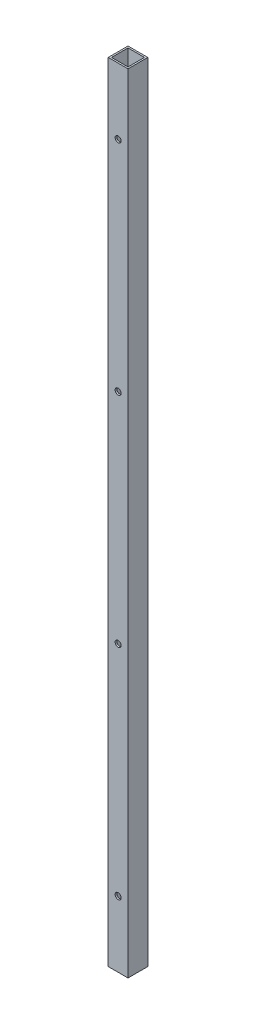
from build123d import *

# Parameters (mm, degrees)
SKETCH1_W                      = 19.05
SKETCH1_H                      = 19.05
SKETCH1_W_2                    = 15.875
SKETCH1_H_2                    = 15.875
TUBE_DEPTH                     = 758.9266
SKETCH2_R                      = 2.8956
SIDE_WALL_HOLES_DEPTH          = 20.05
LPATTERN1_COUNT                = 4
LPATTERN1_PITCH                = 210.574466667
CUT_EXTRUDE1_REACH             = 21.05
SKETCH3_R                      = 4.7625
CUT_EXTRUDE1_DIRECTION_2_DEPTH = 1


with BuildPart() as part:
    # Sketch1 → Tube (new body)
    with BuildSketch(Plane(origin=(0, 0, 0), x_dir=(1, 0, 0), z_dir=(0, 1, 0))):
        Rectangle(SKETCH1_W, SKETCH1_H)
        Rectangle(SKETCH1_W_2, SKETCH1_H_2, mode=Mode.SUBTRACT)
    extrude(amount=TUBE_DEPTH)

    # Sketch2 → Side Wall Holes (cut, through all)
    with BuildSketch(Plane.XY.offset(9.525)):
        with Locations((0, 695.325)):
            Circle(SKETCH2_R)
    side_wall_holes = extrude(amount=-SIDE_WALL_HOLES_DEPTH, mode=Mode.SUBTRACT)

    # LPattern1: Side Wall Holes ×4
    with Locations(*[(0, -i * LPATTERN1_PITCH, 0) for i in range(1, LPATTERN1_COUNT)]):
        add(side_wall_holes, mode=Mode.SUBTRACT)

    # Sketch3 → Cut-Extrude1 (cut, up to next)
    with BuildSketch(Plane.ZY.offset(9.525), mode=Mode.PRIVATE) as cut_extrude1_sk1:
        with Locations((0, 674.37)):
            Circle(SKETCH3_R)
    cut_extrude1_tool1 = extrude(cut_extrude1_sk1.sketch, amount=-CUT_EXTRUDE1_REACH, mode=Mode.PRIVATE) & part.part
    add(cut_extrude1_tool1.solids().sort_by_distance((-9.525, 674.37, 0))[0], mode=Mode.SUBTRACT)
    # Sketch3 → Cut-Extrude1 (cut, up to next)
    with BuildSketch(Plane.ZY.offset(9.525), mode=Mode.PRIVATE) as cut_extrude1_sk2:
        with Locations((0, 84.5566)):
            Circle(SKETCH3_R)
    cut_extrude1_tool2 = extrude(cut_extrude1_sk2.sketch, amount=-CUT_EXTRUDE1_REACH, mode=Mode.PRIVATE) & part.part
    add(cut_extrude1_tool2.solids().sort_by_distance((-9.525, 84.5566, 0))[0], mode=Mode.SUBTRACT)

    # Sketch3 → Cut-Extrude1 direction 2 (cut)
    with BuildSketch(Plane.ZY.offset(9.525)):
        with Locations((0, 674.37)):
            Circle(SKETCH3_R)
        with Locations((0, 84.5566)):
            Circle(SKETCH3_R)
    extrude(amount=CUT_EXTRUDE1_DIRECTION_2_DEPTH, mode=Mode.SUBTRACT)


solid = part.part
